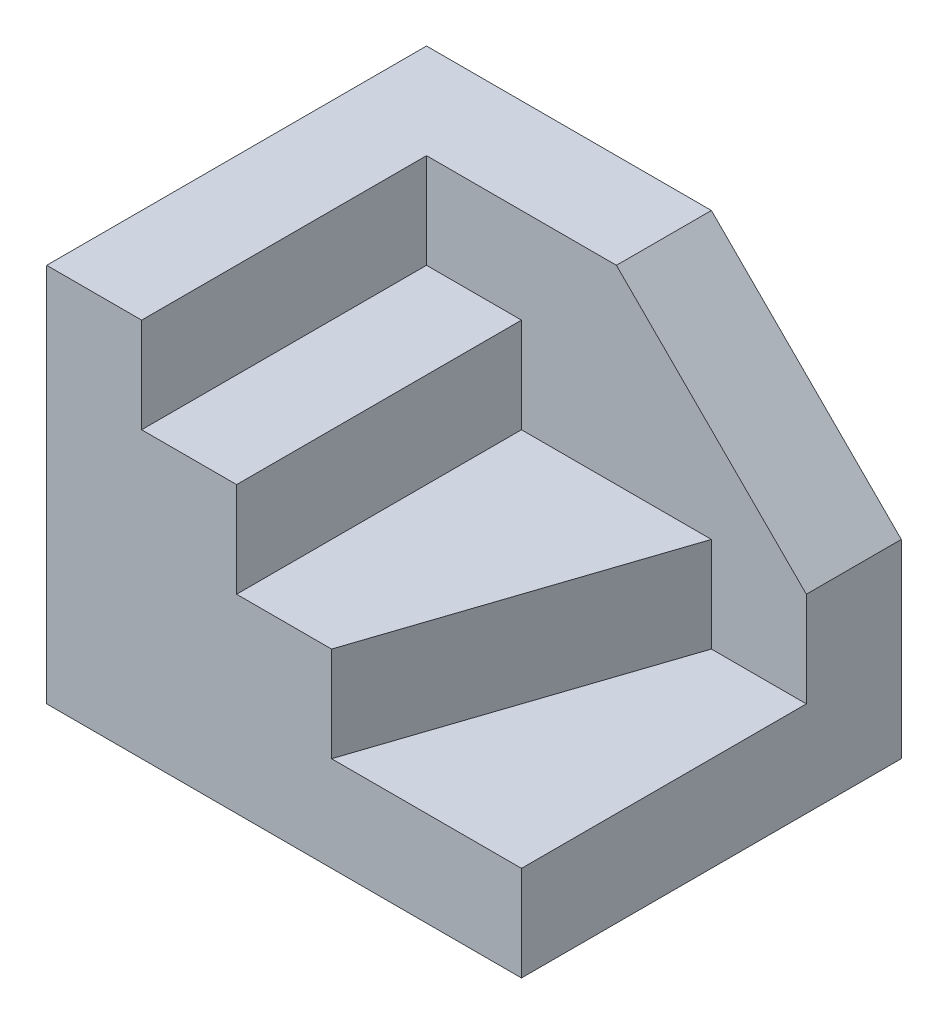
from build123d import *

# Parameters (mm, degrees)
SKETCH_1_W          = 25
SKETCH_1_H          = 20
EXTRUDE_1_DEPTH     = 5
EXTRUDE_2_DEPTH     = 10
SKETCH_1_4_W        = 5
SKETCH_1_4_H        = 15
EXTRUDE_3_DEPTH     = 15
EXTRUDE_4_DEPTH     = 20
CUT_EXTRUDE_1_DEPTH = 20


with BuildPart() as part:
    # 草圖1 → 填料-伸長1 (new body)
    with BuildSketch(Plane(origin=(0, 0, 0), x_dir=(1, 0, 0), z_dir=(0, 1, 0))):
        Rectangle(SKETCH_1_W, SKETCH_1_H)
    extrude(amount=EXTRUDE_1_DEPTH)

    # 草圖1<3> → 填料-伸長2 (add)
    with BuildSketch(Plane(origin=(0, 0, 0), x_dir=(1, 0, 0), z_dir=(0, 1, 0))):
        Polygon((2.5, -10), (7.5, 5), (-2.5, 5), (-2.5, -10), align=None)
    extrude(amount=EXTRUDE_2_DEPTH)

    # 草圖1<4> → 填料-伸長3 (add)
    with BuildSketch(Plane(origin=(0, 0, 0), x_dir=(1, 0, 0), z_dir=(0, 1, 0))):
        with Locations((-5, -2.5)):
            Rectangle(SKETCH_1_4_W, SKETCH_1_4_H)
    extrude(amount=EXTRUDE_3_DEPTH)

    # 草圖1<5> → 填料-伸長4 (add)
    with BuildSketch(Plane(origin=(0, 0, 0), x_dir=(1, 0, 0), z_dir=(0, 1, 0))):
        Polygon((7.5, 5), (12.5, 5), (12.5, 10), (-12.5, 10), (-12.5, -10), (-7.5, -10), (-7.5, 5), (-2.5, 5), align=None)
    extrude(amount=EXTRUDE_4_DEPTH)

    # 草圖2 → 除料-伸長1 (cut)
    with BuildSketch(Plane.XY.offset(-5)):
        Polygon((12.5, 20), (2.5, 20), (12.5, 10), align=None)
    extrude(amount=-CUT_EXTRUDE_1_DEPTH, mode=Mode.SUBTRACT)


solid = part.part
